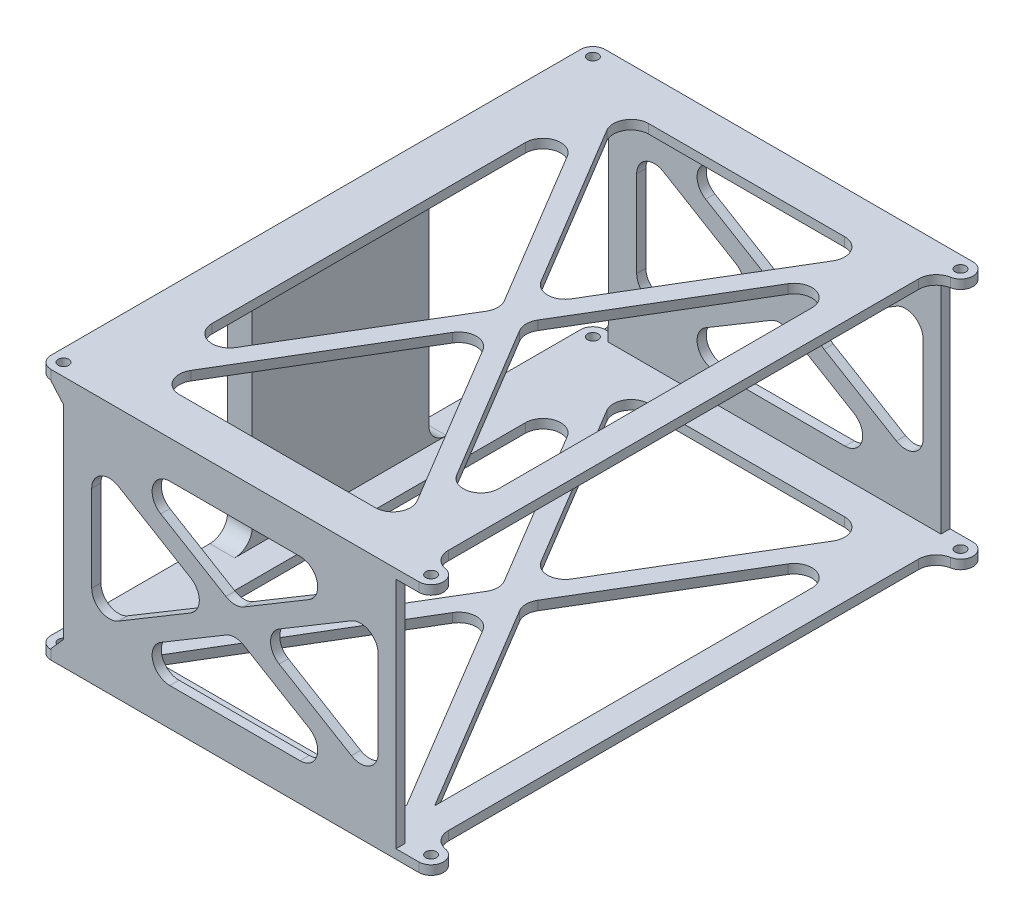
from build123d import *

# Parameters (mm, degrees)
SKETCH3_R               = 1.5
BOSS_EXTRUDE2_DEPTH     = 71.3
SKETCH10_W              = 9.95
SKETCH10_H              = 66.1
CUT_EXTRUDE7_DEPTH      = 157.9
BOSS_EXTRUDE4_REACH     = 113.1
SKETCH14_W              = 50
SKETCH14_H              = 66.1
SKETCH8_W               = 151.7
SKETCH8_H               = 66.1
CUT_EXTRUDE5_DEPTH      = 8
CUT_EXTRUDE5_DEPTH_BACK = 97.1
SKETCH16_W              = 50.85
SKETCH16_H              = 4.25
CUT_EXTRUDE10_DEPTH     = 8
CUT_EXTRUDE11_START     = 66.1
CUT_EXTRUDE11_DEPTH     = 66.1
CUT_EXTRUDE12_DEPTH     = 157.9
CUT_EXTRUDE13_DEPTH     = 72.3
FILLET1_R               = 5


with BuildPart() as part:
    # Sketch3 → Boss-Extrude2 (new body)
    with BuildSketch(Plane(origin=(0, 0, 0), x_dir=(1, 0, 0), z_dir=(0, 1, 0))):
        with BuildLine():
            Line((-48.55, 78.45), (49.2, 78.45))
            Line((49.2, 78.45), (55.55, 78.45))
            ThreePointArc((55.55, 78.45), (59.05, 74.95), (55.55, 71.45))
            Line((55.55, 71.45), (52.05, 71.45))
            Line((52.05, 71.45), (52.05, -71.45))
            Line((52.05, -71.45), (55.55, -71.45))
            ThreePointArc((55.55, -71.45), (59.05, -74.95), (55.55, -78.45))
            Line((55.55, -78.45), (49.2, -78.45))
            Line((49.2, -78.45), (-48.55, -78.45))
            ThreePointArc((-48.55, -78.45), (-51.024873734, -77.424873734), (-52.05, -74.95))
            Line((-52.05, -74.95), (-52.05, 74.95))
            ThreePointArc((-52.05, 74.95), (-51.024873734, 77.424873734), (-48.55, 78.45))
        make_face()
        with Locations((-48.55, 74.95)):
            Circle(SKETCH3_R, mode=Mode.SUBTRACT)
        with Locations((-48.55, -74.95)):
            Circle(SKETCH3_R, mode=Mode.SUBTRACT)
        with Locations((55.55, 74.95)):
            Circle(SKETCH3_R, mode=Mode.SUBTRACT)
        with Locations((55.55, -74.95)):
            Circle(SKETCH3_R, mode=Mode.SUBTRACT)
    extrude(amount=BOSS_EXTRUDE2_DEPTH)

    # Sketch10 → Cut-Extrude7 (cut, through all)
    with BuildSketch(Plane(origin=(0, 0, -78.45), x_dir=(-1, 0, 0), z_dir=(0, 0, -1))):
        Polygon((52.05, 68.7), (48.55, 68.7), (48.55, 68.45), (45.05, 64.45), (45.05, 6.85), (48.55, 2.85), (48.55, 2.6), (52.05, 2.6), align=None)
        with Locations((-54.075, 35.65)):
            Rectangle(SKETCH10_W, SKETCH10_H)
    extrude(amount=-CUT_EXTRUDE7_DEPTH, mode=Mode.SUBTRACT)

    # Sketch14 → Boss-Extrude4 (add, up to next)
    with BuildSketch(Plane.ZY.offset(52.05), mode=Mode.PRIVATE) as boss_extrude4_sk1:
        with Locations((0, 35.65)):
            Rectangle(SKETCH14_W, SKETCH14_H)
    boss_extrude4_tool1 = extrude(boss_extrude4_sk1.sketch, amount=-BOSS_EXTRUDE4_REACH, mode=Mode.PRIVATE) - part.part
    add(boss_extrude4_tool1.solids().sort_by_distance((-52.05, 35.65, 0))[0])

    # Sketch8 → Cut-Extrude5 (cut, two sides)
    with BuildSketch(Plane(origin=(52.05, 0, 0), x_dir=(0, 0, -1), z_dir=(1, 0, 0))) as cut_extrude5_sk:
        with Locations((0, 35.65)):
            Rectangle(SKETCH8_W, SKETCH8_H)
    extrude(amount=CUT_EXTRUDE5_DEPTH, mode=Mode.SUBTRACT)
    extrude(cut_extrude5_sk.sketch, amount=-CUT_EXTRUDE5_DEPTH_BACK, mode=Mode.SUBTRACT)

    # Sketch16 → Cut-Extrude10 (cut, through all)
    with BuildSketch(Plane(origin=(-45.05, 0, 0), x_dir=(0, 0, -1), z_dir=(1, 0, 0))):
        with Locations((-50.425, 66.575)):
            Rectangle(SKETCH16_W, SKETCH16_H)
        with Locations((50.425, 66.575)):
            Rectangle(SKETCH16_W, SKETCH16_H)
        with Locations((50.425, 4.725)):
            Rectangle(SKETCH16_W, SKETCH16_H)
        with Locations((-50.425, 4.725)):
            Rectangle(SKETCH16_W, SKETCH16_H)
    extrude(amount=-CUT_EXTRUDE10_DEPTH, mode=Mode.SUBTRACT)

    # Sketch15 → Cut-Extrude11 (cut)
    with BuildSketch(Plane(origin=(0, 2.6, 0), x_dir=(1, 0, 0), z_dir=(0, 1, 0)).offset(CUT_EXTRUDE11_START)):
        with BuildLine():
            Line((-48.55, 71.45), (-52.05, 71.45))
            Line((-52.05, 71.45), (-52.05, 74.95))
            ThreePointArc((-52.05, 74.95), (-46.075126266, 77.424873734), (-48.55, 71.45))
        make_face()
        with BuildLine():
            Line((-48.55, -71.45), (-52.05, -71.45))
            Line((-52.05, -71.45), (-52.05, -74.95))
            ThreePointArc((-52.05, -74.95), (-46.075126266, -77.424873734), (-48.55, -71.45))
        make_face()
        with BuildLine():
            Line((54.65, -71.45), (54.65, -78.45))
            Line((54.65, -78.45), (55.55, -78.45))
            ThreePointArc((55.55, -78.45), (59.05, -74.95), (55.55, -71.45))
            Line((55.55, -71.45), (54.65, -71.45))
        make_face()
        with BuildLine():
            Line((55.55, 71.45), (54.65, 71.45))
            Line((54.65, 71.45), (54.65, 78.45))
            Line((54.65, 78.45), (55.55, 78.45))
            ThreePointArc((55.55, 78.45), (59.05, 74.95), (55.55, 71.45))
        make_face()
    extrude(amount=-CUT_EXTRUDE11_DEPTH, mode=Mode.SUBTRACT)

    # Sketch18 → Cut-Extrude12 (cut, through all)
    with BuildSketch(Plane.XY.offset(78.45)):
        Polygon((-37.05, 56.7), (-1.844902386, 35.65), (-37.05, 14.6), align=None)
        Polygon((-33.05, 60.7), (40.05, 60.7), (3.5, 38.845849546), align=None)
        Polygon((-33.05, 10.6), (40.05, 10.6), (3.5, 32.454150454), align=None)
        Polygon((44.05, 56.7), (44.05, 14.6), (8.844902386, 35.65), align=None)
    extrude(amount=-CUT_EXTRUDE12_DEPTH, mode=Mode.SUBTRACT)

    # Sketch19 → Cut-Extrude13 (cut, through all)
    with BuildSketch(Plane(origin=(0, 71.3, 0), x_dir=(1, 0, 0), z_dir=(0, 1, 0))):
        Polygon((-37.05, 62.45), (0.303723817, 0), (-37.05, -62.45), align=None)
        Polygon((-33.05, 66.45), (40.05, 66.45), (3.5, 5.343709468), align=None)
        Polygon((-33.05, -66.45), (40.05, -66.45), (3.5, -5.343709468), align=None)
        Polygon((44.05, 62.45), (44.05, -62.45), (6.696276183, 0), align=None)
    extrude(amount=-CUT_EXTRUDE13_DEPTH, mode=Mode.SUBTRACT)

    # Fillet1
    fillet1_edges = [part.edges().sort_by_distance(p)[0] for p in [
        (-33.05, 60.7, 77.15),
        (-37.05, 56.7, 77.15),
        (44.05, 56.7, 77.15),
        (40.05, 60.7, 77.15),
        (40.05, 10.6, 77.15),
        (44.05, 14.6, 77.15),
        (-37.05, 14.6, 77.15),
        (-33.05, 10.6, 77.15),
        (-37.05, 56.7, -77.15),
        (-33.05, 60.7, -77.15),
        (40.05, 60.7, -77.15),
        (44.05, 56.7, -77.15),
        (40.05, 10.6, -77.15),
        (44.05, 14.6, -77.15),
        (-37.05, 14.6, -77.15),
        (-33.05, 10.6, -77.15),
        (3.5, 32.454150454, -77.15),
        (-1.844902386, 35.65, -77.15),
        (3.5, 38.845849546, -77.15),
        (8.844902386, 35.65, -77.15),
        (3.5, 32.454150454, 77.15),
        (-1.844902386, 35.65, 77.15),
        (3.5, 38.845849546, 77.15),
        (8.844902386, 35.65, 77.15),
        (52.05, 1.3, -71.45),
        (52.05, 70, -71.45),
        (52.05, 70, 71.45),
        (52.05, 1.3, 71.45),
        (-37.05, 1.3, -62.45),
        (-33.05, 1.3, -66.45),
        (44.05, 1.3, -62.45),
        (40.05, 1.3, -66.45),
        (3.5, 1.3, -5.343709468),
        (0.303723817, 1.3, 0),
        (3.5, 1.3, 5.343709468),
        (6.696276183, 1.3, 0),
        (-37.05, 70, -62.45),
        (-33.05, 70, -66.45),
        (-37.05, 70, 62.45),
        (-33.05, 70, 66.45),
        (40.05, 70, 66.45),
        (44.05, 70, 62.45),
        (44.05, 70, -62.45),
        (40.05, 70, -66.45),
        (0.303723817, 70, 0),
        (3.5, 70, -5.343709468),
        (6.696276183, 70, 0),
        (3.5, 70, 5.343709468),
        (-48.55, 68.7, -25),
        (-48.55, 2.6, -25),
        (-48.55, 2.6, 25),
        (-48.55, 68.7, 25),
    ]]
    fillet(fillet1_edges, radius=FILLET1_R)


solid = part.part
